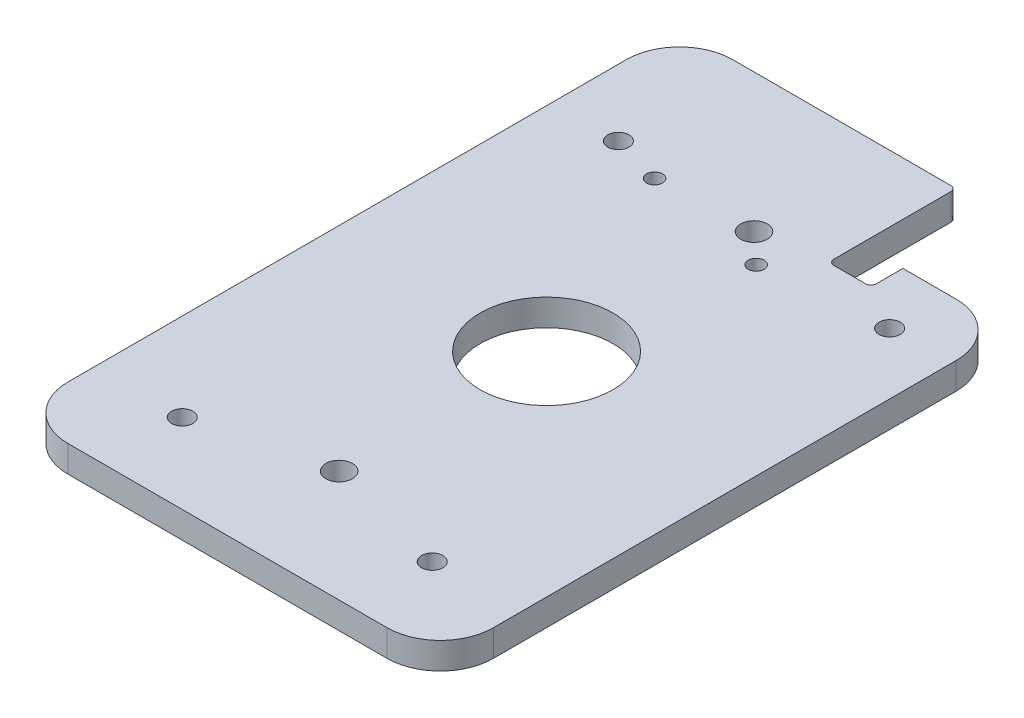
from build123d import *

# Parameters (mm, degrees)
SKETCH_1_W          = 80
SKETCH_1_H          = 125
SKETCH_1_R          = 12.5
EXTRUDE_1_DEPTH     = 5
SKETCH_2_W          = 28
SKETCH_2_H          = 18
CUT_EXTRUDE_1_DEPTH = 6
MM_CLEARANCE_1_D    = 4
MM_TRANSITIONAL_1_D = 5
FILLET_1_R          = 10
MM_TRANSITIONAL_2_D = 3
SKETCH_12_W         = 8
SKETCH_12_H         = 6
CUT_EXTRUDE_2_DEPTH = 6
FILLET_2_R          = 1


with BuildPart() as part:
    # 草图1 → 凸台-拉伸1 (new body)
    with BuildSketch(Plane(origin=(0, 0, 0), x_dir=(1, 0, 0), z_dir=(0, 1, 0))):
        with Locations((0, 2.5)):
            Rectangle(SKETCH_1_W, SKETCH_1_H)
        Circle(SKETCH_1_R, mode=Mode.SUBTRACT)
    extrude(amount=EXTRUDE_1_DEPTH)

    # 草图2 → 切除-拉伸1 (cut, through all)
    with BuildSketch(Plane(origin=(0, 5, 0), x_dir=(1, 0, 0), z_dir=(0, 1, 0))):
        with Locations((26, 56)):
            Rectangle(SKETCH_2_W, SKETCH_2_H)
    extrude(amount=-CUT_EXTRUDE_1_DEPTH, mode=Mode.SUBTRACT)

    # 大小mm Clearance 暗销孔1 (through all)
    with Locations(Plane(origin=(0, 5, 0), x_dir=(1, 0, 0), z_dir=(0, 1, 0))):
        with Locations((-23.5, -45), (23.5, -45), (28.5, 36), (-27.5, 41)):
            Hole(MM_CLEARANCE_1_D / 2)

    # 大小mm Transitional 暗销孔1 (through all)
    with Locations(Plane(origin=(0, 5, 0), x_dir=(1, 0, 0), z_dir=(0, 1, 0))):
        with Locations((0, -39), (0, 39)):
            Hole(MM_TRANSITIONAL_1_D / 2)

    # 圆角1
    fillet_1_edges = [part.edges().sort_by_distance(p)[0] for p in [
        (40, 2.5, -47),
        (-40, 2.5, -65),
        (40, 2.5, 60),
        (-40, 2.5, 60),
    ]]
    fillet(fillet_1_edges, radius=FILLET_1_R)

    # 大小mm Transitional 暗销孔2 (through all)
    with Locations(Plane(origin=(0, 5, 0), x_dir=(1, 0, 0), z_dir=(0, 1, 0))):
        with Locations((5.609431358, 33.8), (-18, 38.3)):
            Hole(MM_TRANSITIONAL_2_D / 2)

    # 草图12 → 切除-拉伸2 (cut, through all)
    with BuildSketch(Plane(origin=(0, 5, 0), x_dir=(1, 0, 0), z_dir=(0, 1, 0))):
        with Locations((16, 44)):
            Rectangle(SKETCH_12_W, SKETCH_12_H)
    extrude(amount=-CUT_EXTRUDE_2_DEPTH, mode=Mode.SUBTRACT)

    # 圆角2
    fillet_2_edges = [part.edges().sort_by_distance(p)[0] for p in [
        (12, 2.5, -41),
        (20, 2.5, -41),
        (12, 2.5, -65),
    ]]
    fillet(fillet_2_edges, radius=FILLET_2_R)


solid = part.part
